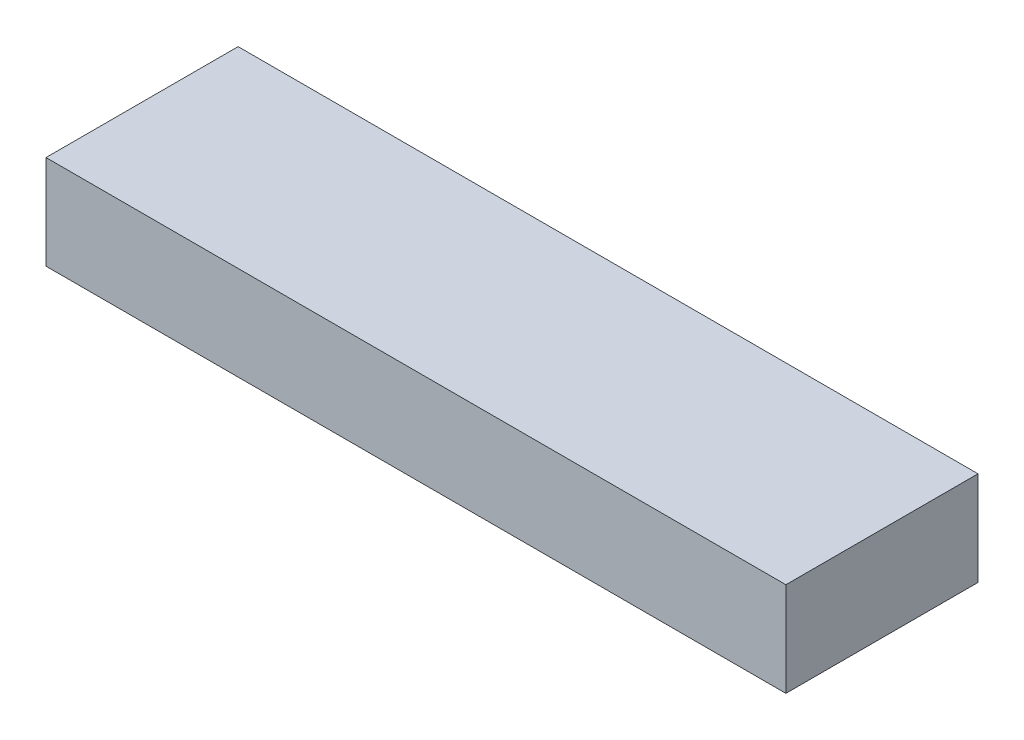
from build123d import *

# Parameters (mm, degrees)
SKETCH1_W           = 1140
SKETCH1_H           = 296
BOSS_EXTRUDE1_DEPTH = 145


with BuildPart() as part:
    # Sketch1 → Boss-Extrude1 (new body)
    with BuildSketch(Plane(origin=(0, 0, 0), x_dir=(1, 0, 0), z_dir=(0, 1, 0))):
        Rectangle(SKETCH1_W, SKETCH1_H)
    extrude(amount=BOSS_EXTRUDE1_DEPTH)


solid = part.part
